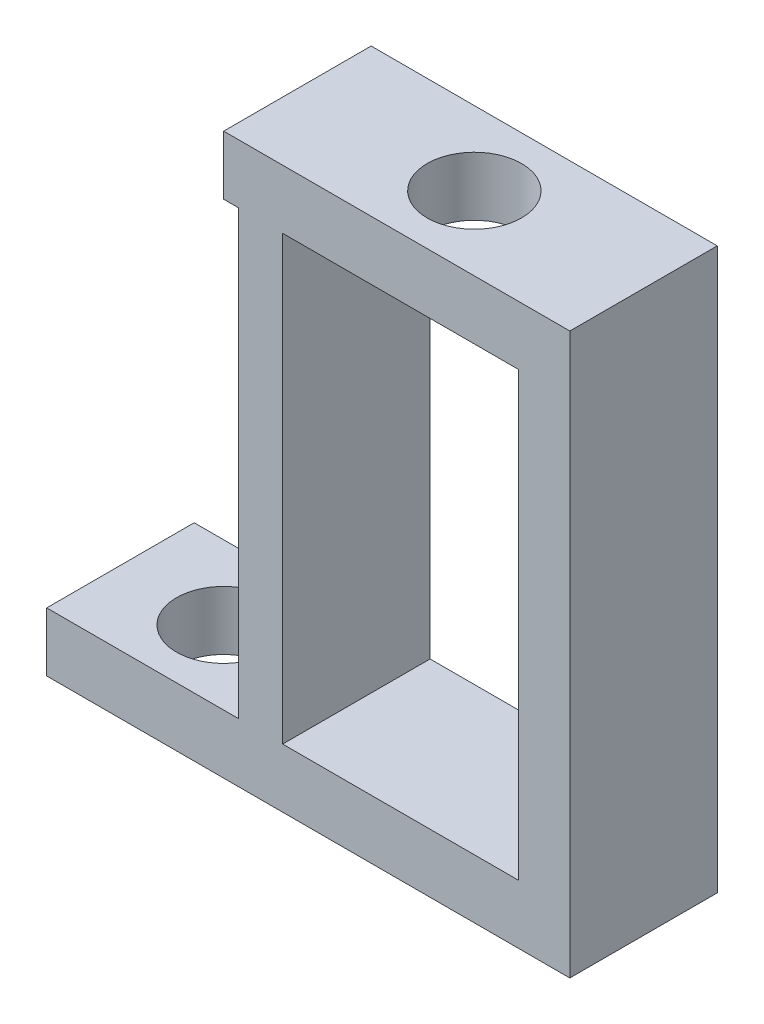
from build123d import *

# Parameters (mm, degrees)
SKETCH1_W           = 10
SKETCH1_H           = 5
SKETCH1_R           = 1.6
BOSS_EXTRUDE2_DEPTH = 2
SKETCH2_W           = 1.5
SKETCH2_H           = 5
BOSS_EXTRUDE3_DEPTH = 15
SKETCH3_W           = 8
SKETCH3_H           = 5
SKETCH3_R           = 1.6
BOSS_EXTRUDE4_DEPTH = 2
BOSS_EXTRUDE5_DEPTH = 5


with BuildPart() as part:
    # Sketch1 → Boss-Extrude2 (new body)
    with BuildSketch(Plane(origin=(0, 0, 0), x_dir=(1, 0, 0), z_dir=(0, 1, 0))):
        with Locations((-2, 0.5)):
            Rectangle(SKETCH1_W, SKETCH1_H)
        with Locations((-1, 0.5)):
            Circle(SKETCH1_R, mode=Mode.SUBTRACT)
    extrude(amount=BOSS_EXTRUDE2_DEPTH)

    # Sketch2 → Boss-Extrude3 (add)
    with BuildSketch(Plane.XZ):
        with Locations((-5.75, -0.5)):
            Rectangle(SKETCH2_W, SKETCH2_H)
    extrude(amount=BOSS_EXTRUDE3_DEPTH)

    # Sketch3 → Boss-Extrude4 (add)
    with BuildSketch(Plane.XZ.offset(15)):
        with Locations((-9, -0.5)):
            Rectangle(SKETCH3_W, SKETCH3_H)
        with Locations((-9.5, -0.5)):
            Circle(SKETCH3_R, mode=Mode.SUBTRACT)
    extrude(amount=BOSS_EXTRUDE4_DEPTH)

    # Sketch4 → Boss-Extrude5 (add)
    with BuildSketch(Plane.XY.offset(2)):
        Polygon((4.737702607, -17), (4.737702607, 2), (3, 2), (3, -15), (-5, -15), (-5, -17), align=None)
    extrude(amount=-BOSS_EXTRUDE5_DEPTH)


solid = part.part
